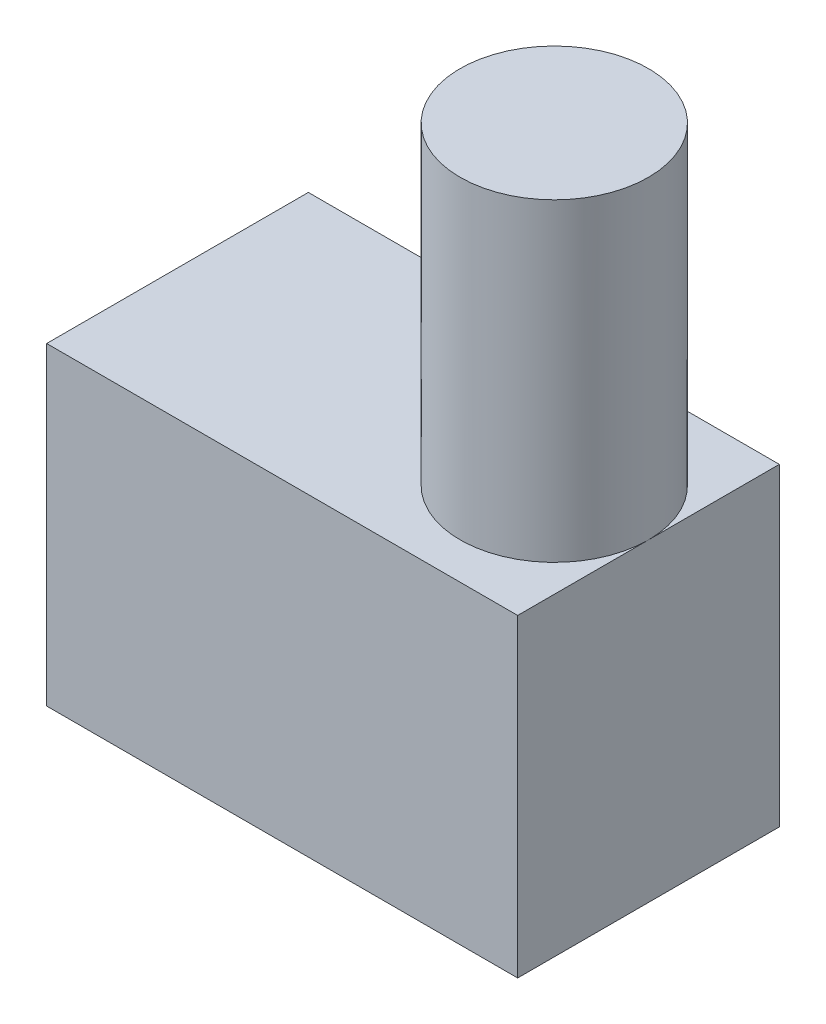
from build123d import *

# Parameters (mm, degrees)
SKETCH1_W           = 45
SKETCH1_H           = 30
BOSS_EXTRUDE1_DEPTH = 25
SKETCH2_R           = 9
BOSS_EXTRUDE2_DEPTH = 30


with BuildPart() as part:
    # Sketch1 → Boss-Extrude1 (new body)
    with BuildSketch(Plane.XY):
        Rectangle(SKETCH1_W, SKETCH1_H)
    extrude(amount=BOSS_EXTRUDE1_DEPTH)

    # Sketch2 → Boss-Extrude2 (add)
    with BuildSketch(Plane(origin=(0, 15, 0), x_dir=(1, 0, 0), z_dir=(0, 1, 0))):
        with Locations((13.5, -12.5)):
            Circle(SKETCH2_R)
    extrude(amount=BOSS_EXTRUDE2_DEPTH)


solid = part.part
